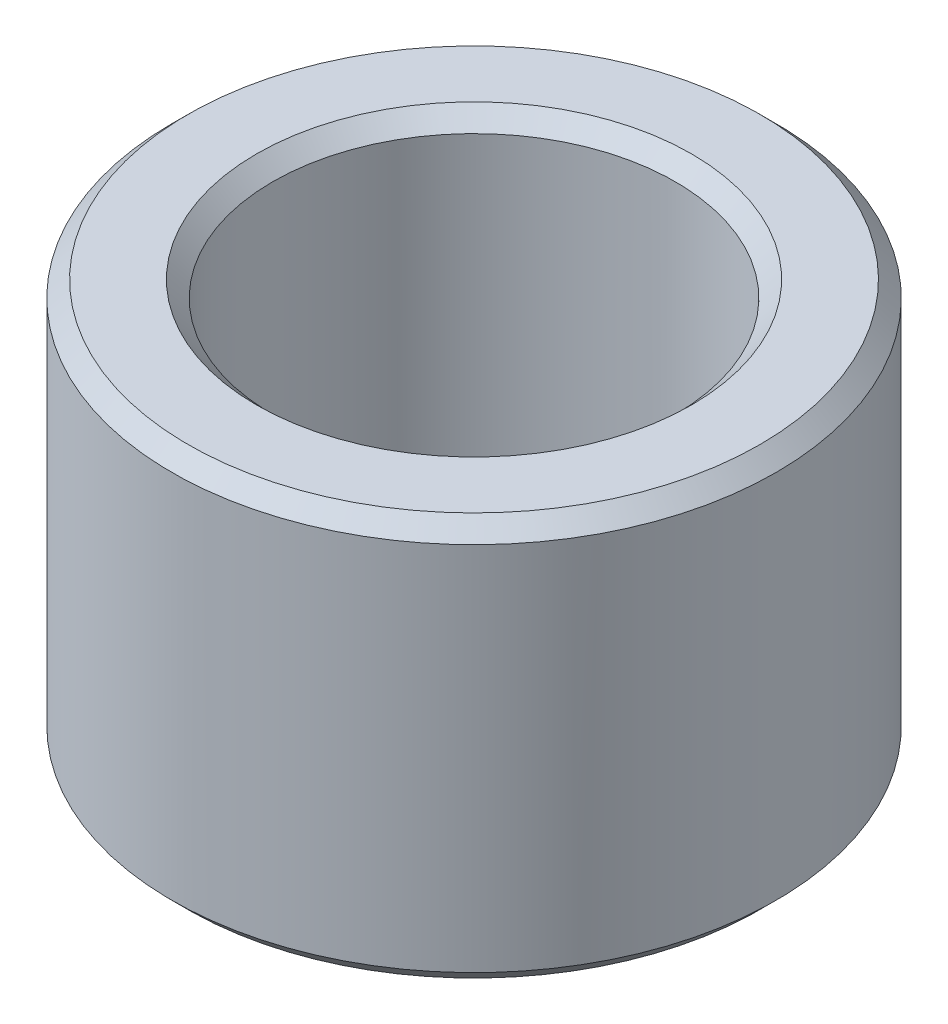
from build123d import *

# Parameters (mm, degrees)
SKETCH1_W     = 1.5875
SKETCH1_H     = 6.35
CHAMFER1_SIZE = 0.254


with BuildPart() as part:
    # Sketch1 → Revolve1 (revolve)
    with BuildSketch(Plane.XY):
        with Locations((3.96875, 0)):
            Rectangle(SKETCH1_W, SKETCH1_H)
    revolve(axis=Axis((0, 2.822643956, 0), (0, -1, 0)))

    # Chamfer1
    chamfer1_edges = [part.edges().sort_by_distance(p)[0] for p in [
        (-4.7625, 3.175, 0),
        (-4.7625, -3.175, 0),
        (-3.175, -3.175, 0),
        (-3.175, 3.175, 0),
    ]]
    chamfer(chamfer1_edges, length=CHAMFER1_SIZE)


solid = part.part
